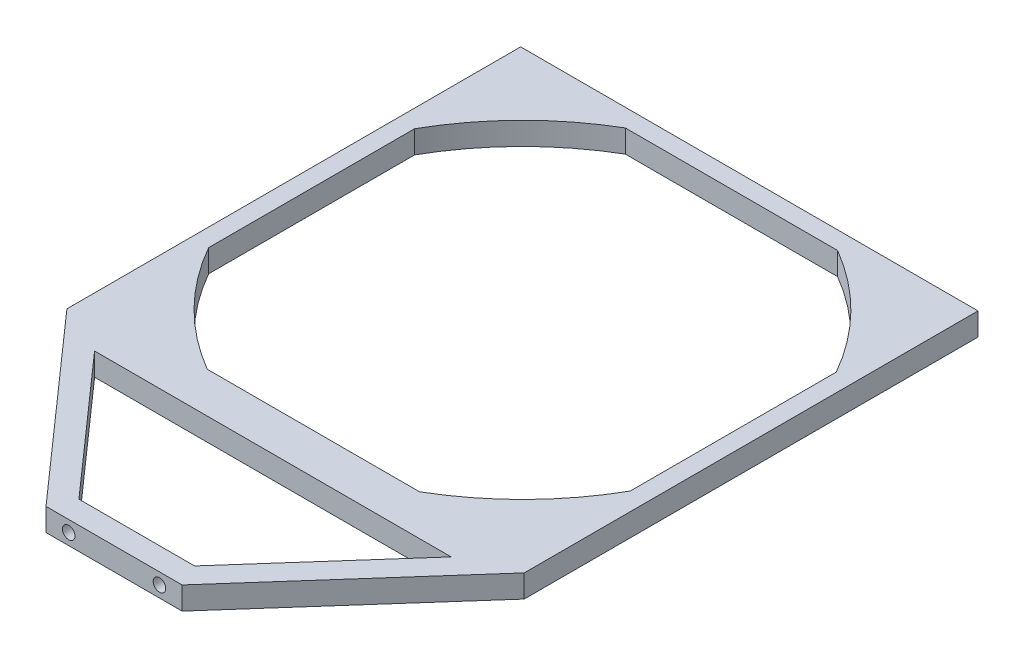
from build123d import *

# Parameters (mm, degrees)
SKETCH2_W                       = 128
SKETCH2_H                       = 127
BOSS_EXTRUDE1_DEPTH             = 6.35
BOSS_EXTRUDE2_DEPTH             = 6.35
F_6_32_TAPPED_HOLE1_D           = 2.7051
F_6_32_TAPPED_HOLE1_DEPTH       = 9.398
F_6_32_TAPPED_HOLE1_CBORE_D     = 3.5052
F_6_32_TAPPED_HOLE1_CBORE_DEPTH = 7.112
F_6_32_TAPPED_HOLE1_TIP         = 0.81269403


with BuildPart() as part:
    # Sketch2 → Boss-Extrude1 (new body)
    with BuildSketch(Plane(origin=(0, 0, 0), x_dir=(1, 0, 0), z_dir=(0, 1, 0))):
        Rectangle(SKETCH2_W, SKETCH2_H)
        with BuildLine():
            Line((29.695725746, 58.5), (-29.695725746, 58.5))
            ThreePointArc((-29.695725746, 58.5), (-46.315550876, 45.606106313), (-59, 28.825884855))
            Line((-59, 28.825884855), (-59, -28.825884855))
            ThreePointArc((-59, -28.825884855), (-46.315550876, -45.606106313), (-29.695725746, -58.5))
            Line((-29.695725746, -58.5), (29.695725746, -58.5))
            ThreePointArc((29.695725746, -58.5), (46.315550876, -45.606106313), (59, -28.825884855))
            Line((59, -28.825884855), (59, 28.825884855))
            ThreePointArc((59, 28.825884855), (46.315550876, 45.606106313), (29.695725746, 58.5))
        make_face(mode=Mode.SUBTRACT)
    extrude(amount=BOSS_EXTRUDE1_DEPTH)

    # Sketch3 → Boss-Extrude2 (add)
    with BuildSketch(Plane(origin=(0, 6.35, 0), x_dir=(1, 0, 0), z_dir=(0, 1, 0))):
        Polygon((-64, -63.5), (-19.05, -114.3), (19.05, -114.3), (64, -63.5), align=None)
        Polygon((-49.902284759, -69.85), (-16.189784759, -107.95), (16.189784759, -107.95), (49.902284759, -69.85), align=None, mode=Mode.SUBTRACT)
    extrude(amount=-BOSS_EXTRUDE2_DEPTH)

    # #6-32 Tapped Hole1
    with Locations(Plane.XY.offset(114.3)):
        with Locations((-12.7, 3.175), (12.7, 3.175)):
            CounterBoreHole(F_6_32_TAPPED_HOLE1_D / 2, F_6_32_TAPPED_HOLE1_CBORE_D / 2, F_6_32_TAPPED_HOLE1_CBORE_DEPTH, depth=F_6_32_TAPPED_HOLE1_DEPTH)
            with Locations((0, 0, -(F_6_32_TAPPED_HOLE1_DEPTH + F_6_32_TAPPED_HOLE1_TIP / 2))):  # 118° drill point
                Cone(0, F_6_32_TAPPED_HOLE1_D / 2, F_6_32_TAPPED_HOLE1_TIP, mode=Mode.SUBTRACT)


solid = part.part
